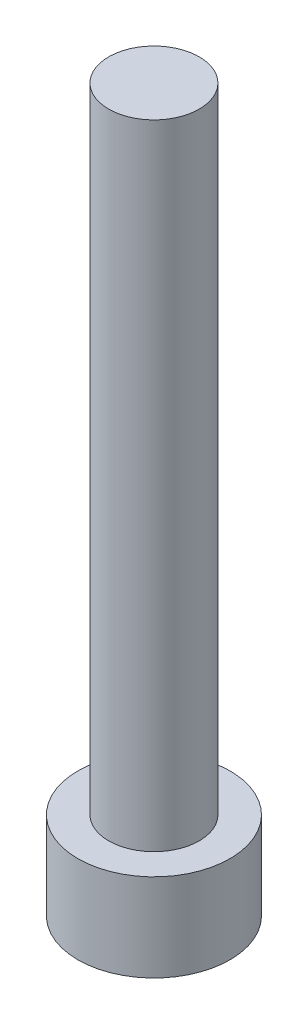
from build123d import *

# Parameters (mm, degrees)
SKETCH_1_R          = 4.2
EXTRUDE_1_DEPTH     = 4.84
SKETCH_2_R          = 2.5
EXTRUDE_2_DEPTH     = 35
CUT_EXTRUDE_1_DEPTH = 3.4


with BuildPart() as part:
    # 草图1 → 凸台-拉伸1 (new body)
    with BuildSketch(Plane(origin=(0, 0, 0), x_dir=(1, 0, 0), z_dir=(0, 1, 0))):
        Circle(SKETCH_1_R)
    extrude(amount=EXTRUDE_1_DEPTH)

    # 草图2 → 凸台-拉伸2 (add)
    with BuildSketch(Plane(origin=(0, 4.84, 0), x_dir=(1, 0, 0), z_dir=(0, 1, 0))):
        Circle(SKETCH_2_R)
    extrude(amount=EXTRUDE_2_DEPTH)

    # 草图3 → 切除-拉伸1 (cut)
    with BuildSketch(Plane.XZ):
        Polygon((2.3, 0), (1.15, 1.991858429), (-1.15, 1.991858429), (-2.3, 0), (-1.15, -1.991858429), (1.15, -1.991858429), align=None)
    extrude(amount=-CUT_EXTRUDE_1_DEPTH, mode=Mode.SUBTRACT)


solid = part.part
